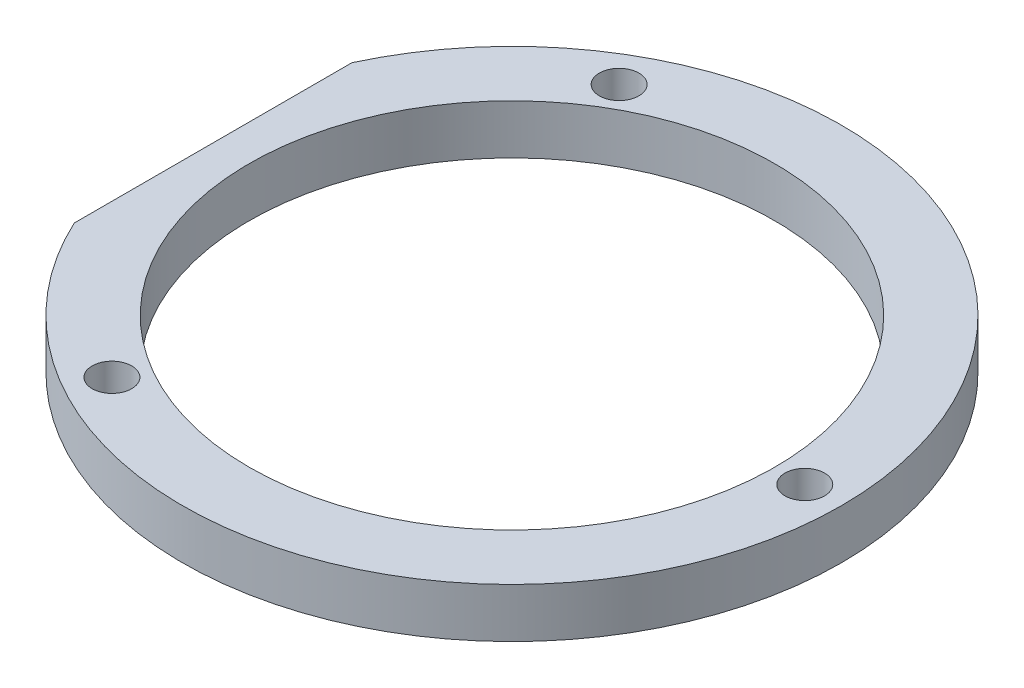
from build123d import *

# Parameters (mm, degrees)
SKETCH_1_R               = 26.64
EXTRUDE_1_DEPTH          = 4
SKETCH_2_R               = 21.25
CUT_EXTRUDE_1_DEPTH      = 4
SKETCH_3_R               = 1.6
CUT_EXTRUDE_2_DEPTH      = 4
PATTERN_CIRCULAR_1_COUNT = 3
SKETCH_5_W               = 17.203489066
SKETCH_5_H               = 59.100654928
CUT_EXTRUDE_3_DEPTH      = 4


with BuildPart() as part:
    # 草图1 → 凸台-拉伸1 (new body)
    with BuildSketch(Plane(origin=(0, 0, 0), x_dir=(1, 0, 0), z_dir=(0, 1, 0))):
        Circle(SKETCH_1_R)
    extrude(amount=EXTRUDE_1_DEPTH)

    # 草图2 → 切除-拉伸1 (cut)
    with BuildSketch(Plane(origin=(0, 4, 0), x_dir=(1, 0, 0), z_dir=(0, 1, 0))):
        Circle(SKETCH_2_R)
    extrude(amount=-CUT_EXTRUDE_1_DEPTH, mode=Mode.SUBTRACT)

    # 草图3 → 切除-拉伸2 (cut)
    with BuildSketch(Plane(origin=(0, 4, 0), x_dir=(1, 0, 0), z_dir=(0, 1, 0))):
        with Locations((23.672055427, 0)):
            Circle(SKETCH_3_R)
    cut_extrude_2 = extrude(amount=-CUT_EXTRUDE_2_DEPTH, mode=Mode.SUBTRACT)

    # 阵列(圆周)1: 切除-拉伸2 ×3 about axis
    pattern_circular_1_axis = Axis((0, 0, 0), (0, 1, 0))
    for i in range(1, PATTERN_CIRCULAR_1_COUNT):
        add(cut_extrude_2.rotate(pattern_circular_1_axis, i * 360 / PATTERN_CIRCULAR_1_COUNT), mode=Mode.SUBTRACT)

    # 草图5 → 切除-拉伸3 (cut)
    with BuildSketch(Plane(origin=(0, 4, 0), x_dir=(1, 0, 0), z_dir=(0, 1, 0))):
        with Locations((-32.761744533, -1.256680407)):
            Rectangle(SKETCH_5_W, SKETCH_5_H)
    extrude(amount=-CUT_EXTRUDE_3_DEPTH, mode=Mode.SUBTRACT)


solid = part.part
